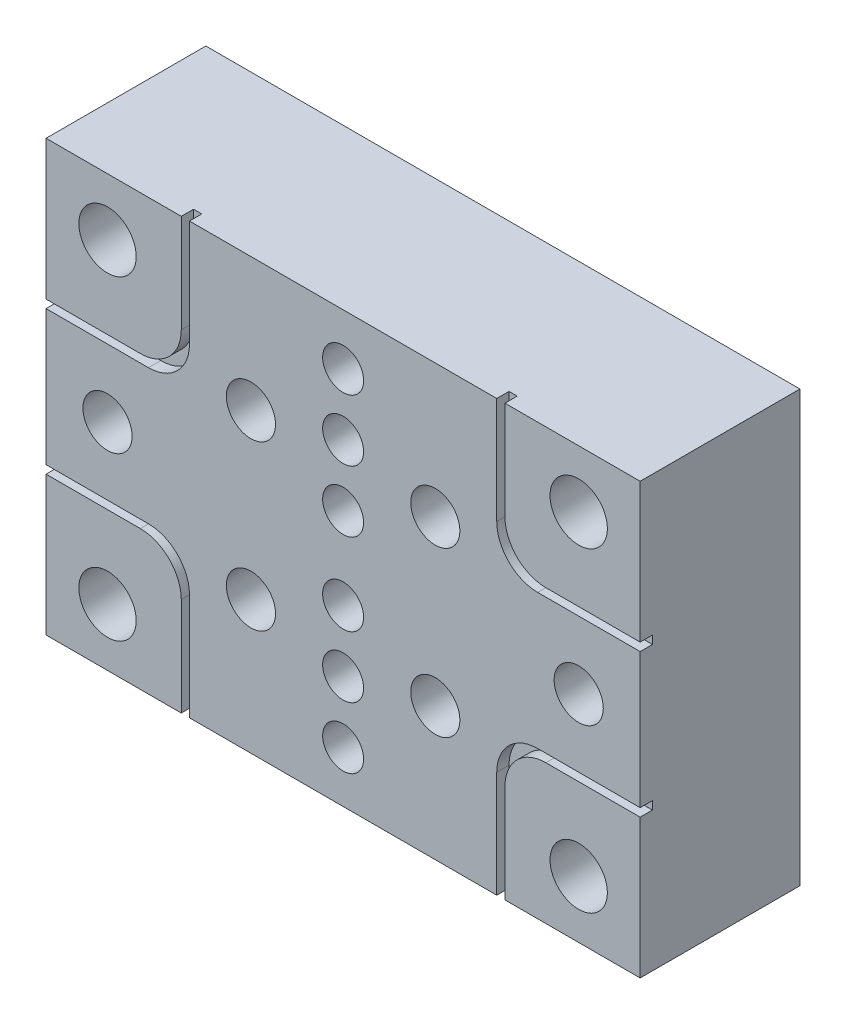
from build123d import *

# Parameters (mm, degrees)
CROQUIS1_W                              = 145
CROQUIS1_H                              = 105
SALIENTE_EXTRUIR1_DEPTH                 = 39
TALADRO1_D                              = 14
SIMETR_A2_COPY_1_D                      = 14
TALADRO_DE_MARGEN_PARA_M1_61_AT_2_COUNT = 2
TALADRO_DE_MARGEN_PARA_M1_61_AT_2_PITCH = 15
TALADRO_DE_MARGEN_PARA_M1_61_AT_3_COUNT = 2
TALADRO_DE_MARGEN_PARA_M1_61_AT_3_PITCH = 30
TALADRO_DE_MARGEN_PARA_M1_62_AT_2_COUNT = 2
TALADRO_DE_MARGEN_PARA_M1_62_AT_2_PITCH = 40.311288741
TALADRO_DE_MARGEN_PARA_M1_62_AT_3_COUNT = 2
TALADRO_DE_MARGEN_PARA_M1_62_AT_3_PITCH = 40.311288741
CORTAR_EXTRUIR1_DEPTH                   = 3
SIMETR_A6_COPY_1_DEPTH                  = 3


with BuildPart() as part:
    # Croquis1 → Saliente-Extruir1 (new body)
    with BuildSketch(Plane.XY):
        Rectangle(CROQUIS1_W, CROQUIS1_H)
    extrude(amount=SALIENTE_EXTRUIR1_DEPTH)

    # Taladro1 (through all)
    with Locations(Plane.XY.offset(39)):
        with Locations((-57.5, 38.5)):
            taladro1 = Hole(TALADRO1_D / 2)

    # Simetría1: Taladro1 across plane
    add(taladro1.mirror(Plane.ZX), mode=Mode.SUBTRACT)

    # Simetría2: Taladro1 across plane
    add(taladro1.mirror(Plane(origin=(0, 0, 0), x_dir=(0, 0, 1), z_dir=(1, 0, 0))), mode=Mode.SUBTRACT)

    # Simetría2 copy 1 (through all)
    with Locations(Plane(origin=(0, 0, 39), x_dir=(-1, 0, 0), z_dir=(0, 0, 1))):
        with Locations((-57.5, 38.5)):
            Hole(SIMETR_A2_COPY_1_D / 2)

    # Croquis7 → Taladro de margen para M1.61 (revolve, cut)
    with BuildSketch(Plane(origin=(0, 40, 39), x_dir=(0, -1, 0), z_dir=(1, 0, 0))):
        Polygon((0, 0), (0, 28.004303095), (5, 25), (5, 0), align=None)
    taladro_de_margen_para_m1_61 = revolve(axis=Axis((0, 40, 45.35), (0, 0, -1)), mode=Mode.SUBTRACT)

    # Taladro de margen para M1.61 at 2: Taladro de margen para M1.61 ×2
    with Locations(*[(0, -i * TALADRO_DE_MARGEN_PARA_M1_61_AT_2_PITCH, 0) for i in range(1, TALADRO_DE_MARGEN_PARA_M1_61_AT_2_COUNT)]):
        add(taladro_de_margen_para_m1_61, mode=Mode.SUBTRACT)

    # Taladro de margen para M1.61 at 3: Taladro de margen para M1.61 ×2
    with Locations(*[(0, -i * TALADRO_DE_MARGEN_PARA_M1_61_AT_3_PITCH, 0) for i in range(1, TALADRO_DE_MARGEN_PARA_M1_61_AT_3_COUNT)]):
        add(taladro_de_margen_para_m1_61, mode=Mode.SUBTRACT)

    # Simetría3: Taladro de margen para M1.61 across plane
    add(taladro_de_margen_para_m1_61.mirror(Plane.ZX), mode=Mode.SUBTRACT)

    # Simetría3 copy 1 sketch → Simetría3 copy 1 (revolve, cut)
    with BuildSketch(Plane(origin=(0, -25, 39), x_dir=(0, 1, 0), z_dir=(1, 0, 0))):
        Polygon((0, 0), (0, -28.004303095), (5, -25), (5, 0), align=None)
    revolve(axis=Axis((0, -25, 45.35), (0, 0, 1)), mode=Mode.SUBTRACT)

    # Simetría3 copy 2 sketch → Simetría3 copy 2 (revolve, cut)
    with BuildSketch(Plane(origin=(0, -10, 39), x_dir=(0, 1, 0), z_dir=(1, 0, 0))):
        Polygon((0, 0), (0, -28.004303095), (5, -25), (5, 0), align=None)
    revolve(axis=Axis((0, -10, 45.35), (0, 0, 1)), mode=Mode.SUBTRACT)

    # Croquis9 → Taladro de margen para M1.62 (revolve, cut)
    with BuildSketch(Plane(origin=(-57.5, 0, 39), x_dir=(0, -1, 0), z_dir=(1, 0, 0))):
        Polygon((0, 0), (0, 21.605163714), (6, 18), (6, 0), align=None)
    taladro_de_margen_para_m1_62 = revolve(axis=Axis((-57.5, 0, 45.35), (0, 0, -1)), mode=Mode.SUBTRACT)

    # Taladro de margen para M1.62 at 2: Taladro de margen para M1.62 ×2
    with Locations(*[Vector(0.868243142, 0.496138938, 0) * (i * TALADRO_DE_MARGEN_PARA_M1_62_AT_2_PITCH) for i in range(1, TALADRO_DE_MARGEN_PARA_M1_62_AT_2_COUNT)]):
        add(taladro_de_margen_para_m1_62, mode=Mode.SUBTRACT)

    # Taladro de margen para M1.62 at 3: Taladro de margen para M1.62 ×2
    with Locations(*[Vector(0.868243142, -0.496138938, 0) * (i * TALADRO_DE_MARGEN_PARA_M1_62_AT_3_PITCH) for i in range(1, TALADRO_DE_MARGEN_PARA_M1_62_AT_3_COUNT)]):
        add(taladro_de_margen_para_m1_62, mode=Mode.SUBTRACT)

    # Simetría4: Taladro de margen para M1.62 across plane
    add(taladro_de_margen_para_m1_62.mirror(Plane(origin=(0, 0, 0), x_dir=(0, 0, 1), z_dir=(1, 0, 0))), mode=Mode.SUBTRACT)

    # Simetría4 copy 1 sketch → Simetría4 copy 1 (revolve, cut)
    with BuildSketch(Plane(origin=(22.5, 20, 39), x_dir=(0, -1, 0), z_dir=(-1, 0, 0))):
        Polygon((0, 0), (0, -21.605163714), (6, -18), (6, 0), align=None)
    revolve(axis=Axis((22.5, 20, 45.35), (0, 0, 1)), mode=Mode.SUBTRACT)

    # Simetría4 copy 2 sketch → Simetría4 copy 2 (revolve, cut)
    with BuildSketch(Plane(origin=(22.5, -20, 39), x_dir=(0, -1, 0), z_dir=(-1, 0, 0))):
        Polygon((0, 0), (0, -21.605163714), (6, -18), (6, 0), align=None)
    revolve(axis=Axis((22.5, -20, 45.35), (0, 0, 1)), mode=Mode.SUBTRACT)

    # Croquis10 → Cortar-Extruir1 (cut)
    with BuildSketch(Plane.XY.offset(39)):
        with BuildLine():
            Line((-37.5, 52.5), (-37.5, 26.5))
            ThreePointArc((-37.5, 26.5), (-40.428932188, 19.428932188), (-47.5, 16.5))
            Line((-47.5, 16.5), (-72.5, 16.5))
            Line((-72.5, 16.5), (-72.5, 18.5))
            Line((-72.5, 18.5), (-49.5, 18.5))
            ThreePointArc((-49.5, 18.5), (-42.428932188, 21.428932188), (-39.5, 28.5))
            Line((-39.5, 28.5), (-39.5, 52.5))
            Line((-39.5, 52.5), (-37.5, 52.5))
        make_face()
    cortar_extruir1 = extrude(amount=-CORTAR_EXTRUIR1_DEPTH, mode=Mode.SUBTRACT)

    # Simetría5: Cortar-Extruir1 across plane
    add(cortar_extruir1.mirror(Plane.ZX), mode=Mode.SUBTRACT)

    # Simetría6: Cortar-Extruir1 across plane
    add(cortar_extruir1.mirror(Plane(origin=(0, 0, 0), x_dir=(0, 0, 1), z_dir=(1, 0, 0))), mode=Mode.SUBTRACT)

    # Simetría6 copy 1 sketch → Simetría6 copy 1 (cut)
    with BuildSketch(Plane(origin=(0, 0, 39), x_dir=(-1, 0, 0), z_dir=(0, 0, 1))):
        with BuildLine():
            Line((-37.5, 52.5), (-37.5, 26.5))
            ThreePointArc((-37.5, 26.5), (-40.428932188, 19.428932188), (-47.5, 16.5))
            Line((-47.5, 16.5), (-72.5, 16.5))
            Line((-72.5, 16.5), (-72.5, 18.5))
            Line((-72.5, 18.5), (-49.5, 18.5))
            ThreePointArc((-49.5, 18.5), (-42.428932188, 21.428932188), (-39.5, 28.5))
            Line((-39.5, 28.5), (-39.5, 52.5))
            Line((-39.5, 52.5), (-37.5, 52.5))
        make_face()
    extrude(amount=-SIMETR_A6_COPY_1_DEPTH, mode=Mode.SUBTRACT)


solid = part.part
